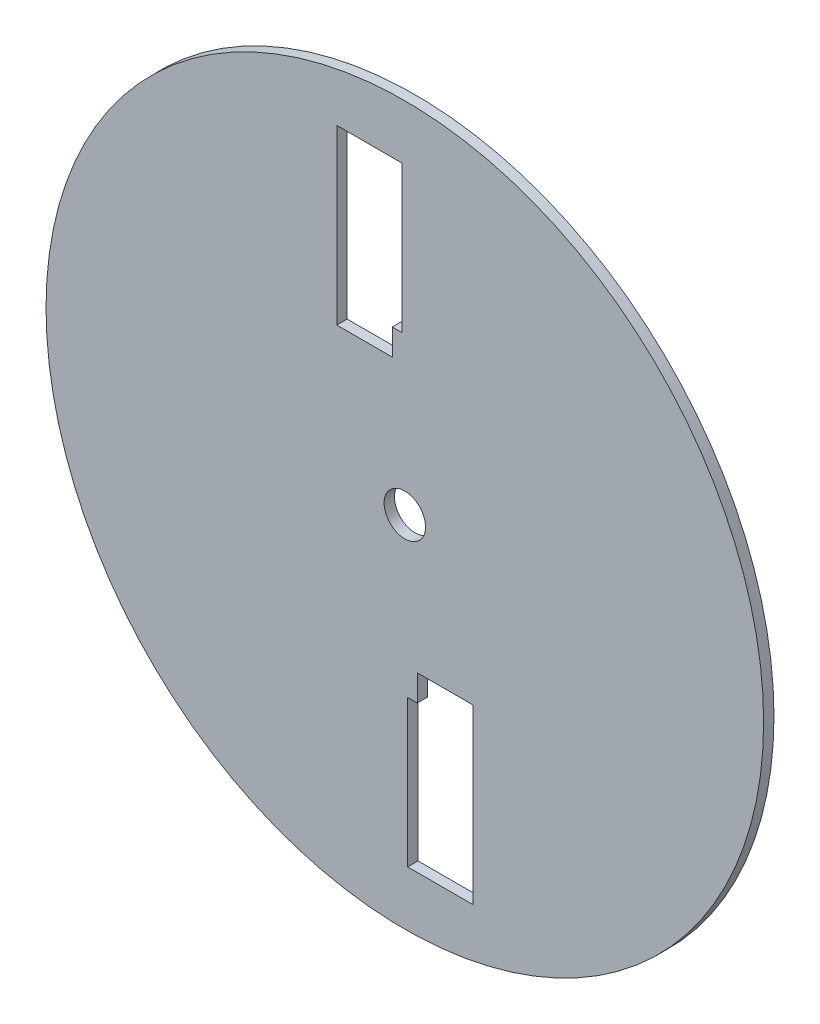
from build123d import *

# Parameters (mm, degrees)
SKETCH1_R           = 110
SKETCH1_R_2         = 6.35
BOSS_EXTRUDE1_DEPTH = 1.5875


with BuildPart() as part:
    # Sketch1 → Boss-Extrude1 (new body, symmetric)
    with BuildSketch(Plane.XY):
        Circle(SKETCH1_R)
        Circle(SKETCH1_R_2, mode=Mode.SUBTRACT)
        Polygon((-6.35, 40), (-3.85, 40), (-3.85, 48), (-0.85, 48), (-0.85, 93), (-20.85, 93), (-20.85, 40), (-18.35, 40), align=None, mode=Mode.SUBTRACT)
        Polygon((6.35, -40), (3.85, -40), (3.85, -48), (0.85, -48), (0.85, -93), (20.85, -93), (20.85, -40), (18.35, -40), align=None, mode=Mode.SUBTRACT)
    extrude(amount=BOSS_EXTRUDE1_DEPTH, both=True)


solid = part.part
